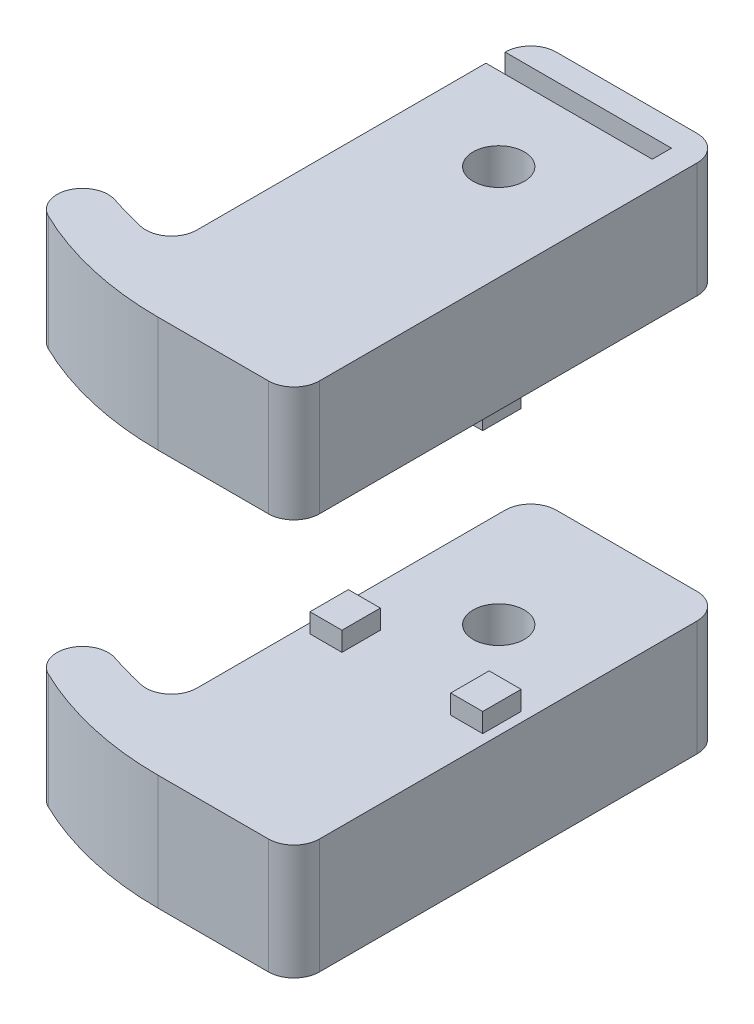
from build123d import *

# Parameters (mm, degrees)
SKETCH_1_R          = 2
EXTRUDE_1_DEPTH     = 9
SKETCH_3_W          = 2.5
SKETCH_3_H          = 3
EXTRUDE_2_DEPTH     = 1.5
CUT_EXTRUDE_1_REACH = 13
CUT_EXTRUDE_START   = -2
SKETCH_5_W          = 13
SKETCH_5_H          = 1.5
SKETCH_9_W          = 49.545975543
SKETCH_9_H          = 42.208236046
CUT_EXTRUDE_2_DEPTH = 11.5


with BuildPart() as part:
    # 草图1 → 凸台-拉伸1 (new body)
    with BuildSketch(Plane(origin=(0, 0, 0), x_dir=(1, 0, 0), z_dir=(0, 1, 0))):
        with BuildLine():
            Line((-2.382835885, 33.5), (8.617164115, 33.5))
            ThreePointArc((8.617164115, 33.5), (10.031377677, 32.914213562), (10.617164115, 31.5))
            Line((10.617164115, 31.5), (10.617164115, 2))
            ThreePointArc((10.617164115, 2), (10.031377677, 0.585786438), (8.617164115, 0))
            Line((8.617164115, 0), (0, 0))
            ThreePointArc((0, 0), (-5.710600422, 0.647655185), (-11.131122415, 2.557722132))
            ThreePointArc((-11.131122415, 2.557722132), (-12.111898361, 5.107720531), (-9.633282348, 6.257014206))
            ThreePointArc((-9.633282348, 6.257014206), (-8.243555708, 5.833986106), (-6.836394497, 5.473167269))
            ThreePointArc((-6.836394497, 5.473167269), (-5.139275919, 5.854675685), (-4.382835885, 7.421059613))
            Line((-4.382835885, 7.421059613), (-4.382835885, 31.5))
            ThreePointArc((-4.382835885, 31.5), (-3.797049447, 32.914213562), (-2.382835885, 33.5))
        make_face()
        with Locations((3.117164115, 23.5)):
            Circle(SKETCH_1_R, mode=Mode.SUBTRACT)
    extrude(amount=EXTRUDE_1_DEPTH)

    # 草图3 → 凸台-拉伸2 (add)
    with BuildSketch(Plane(origin=(0, 9, 0), x_dir=(1, 0, 0), z_dir=(0, 1, 0))):
        with Locations((-2.382835885, 17)):
            Rectangle(SKETCH_3_W, SKETCH_3_H)
        with Locations((8.617164115, 17)):
            Rectangle(SKETCH_3_W, SKETCH_3_H)
    extrude(amount=EXTRUDE_2_DEPTH)

    # 草图5 → 切除-拉伸1 (cut, up to next)
    with BuildSketch(Plane(origin=(0, 9, 0), x_dir=(1, 0, 0), z_dir=(0, 1, 0)).offset(CUT_EXTRUDE_START), mode=Mode.PRIVATE) as cut_extrude_1_sk1:
        with Locations((2.117164115, 30.75)):
            Rectangle(SKETCH_5_W, SKETCH_5_H)
    cut_extrude_1_tool1 = extrude(cut_extrude_1_sk1.sketch, amount=-CUT_EXTRUDE_1_REACH, mode=Mode.PRIVATE) & part.part
    add(cut_extrude_1_tool1.solids().sort_by_distance((2.117164, 7, -30.75))[0], mode=Mode.SUBTRACT)

    # 镜向8: part across plane


with BuildPart() as part_1:
    add(part.part)
    add(part.part.mirror(Plane(origin=(0, 0, -25.5), x_dir=(0, 0, 1), z_dir=(0, -1, 0))))

    # 草图9 → 切除-拉伸2 (cut, through all)
    with BuildSketch(Plane(origin=(0, 0, 0), x_dir=(1, 0, 0), z_dir=(0, 1, 0))):
        with Locations((0.218507418, 15.905835279)):
            Rectangle(SKETCH_9_W, SKETCH_9_H)
    extrude(amount=-CUT_EXTRUDE_2_DEPTH, mode=Mode.SUBTRACT)


with BuildPart() as body_2:
    # 镜向11: mirrored copy
    add(part_1.part.mirror(Plane(origin=(0, 20, 0), x_dir=(0, 0, 1), z_dir=(0, -1, 0))))


solid = Compound([part_1.part, body_2.part])
